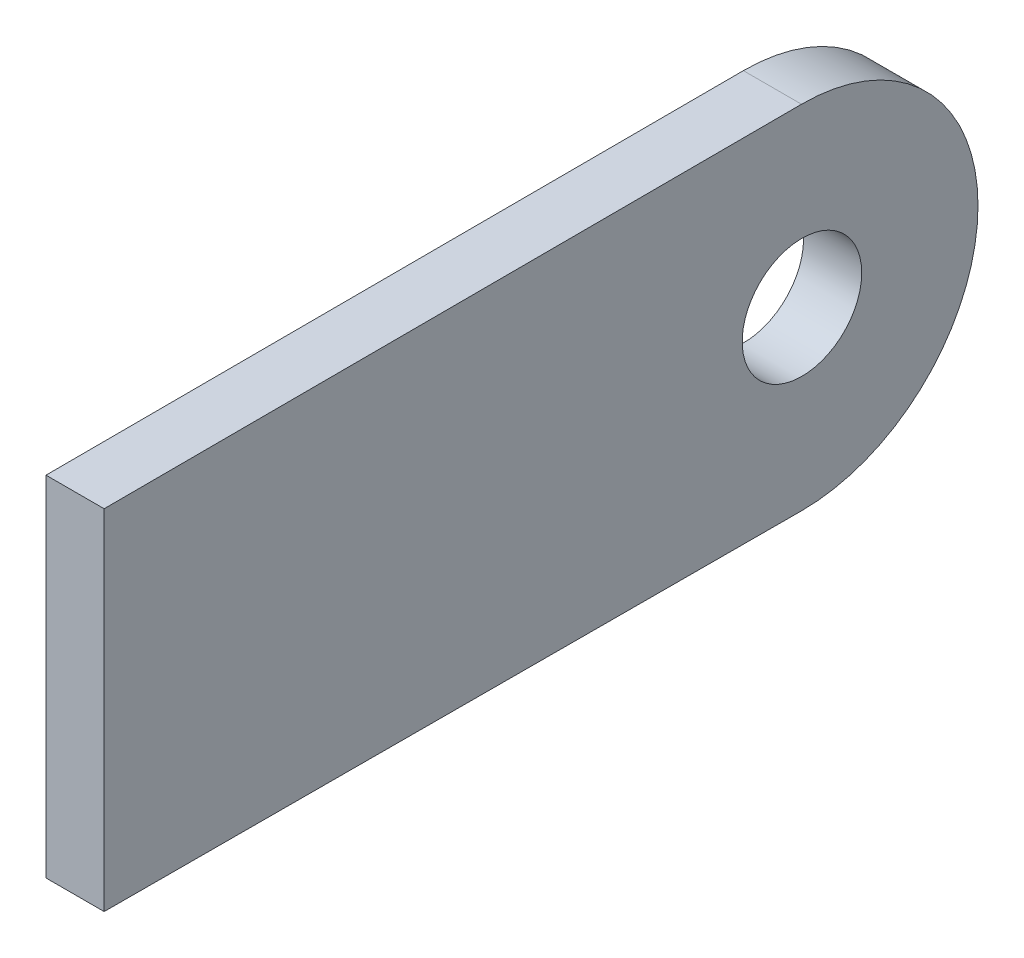
from build123d import *

# Parameters (mm, degrees)
SKETCH1_R           = 3.2639
BOSS_EXTRUDE1_DEPTH = 1.5875


with BuildPart() as part:
    # Sketch1 → Boss-Extrude1 (new body, symmetric)
    with BuildSketch(Plane(origin=(0, 0, 0), x_dir=(0, 0, -1), z_dir=(1, 0, 0))):
        with BuildLine():
            Line((-38.1, 9.525), (-38.1, -9.525))
            Line((-38.1, -9.525), (-0.02243898, -9.613873814))
            ThreePointArc((-0.02243898, -9.613873814), (9.6139, 0), (-0.02243898, 9.613873814))
            Line((-0.02243898, 9.613873814), (-38.1, 9.525))
        make_face()
        Circle(SKETCH1_R, mode=Mode.SUBTRACT)
    extrude(amount=BOSS_EXTRUDE1_DEPTH, both=True)


solid = part.part
